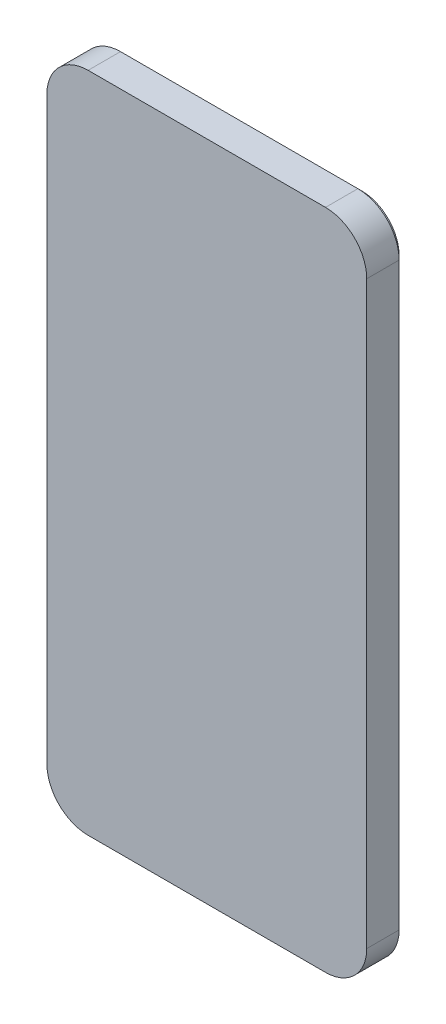
from build123d import *

# Parameters (mm, degrees)
IZIM1_W                     = 77.58
IZIM1_H                     = 160.7
Y_KSEKLIK_EKSTR_ZYON1_DEPTH = 7.85
RADYUS1_R                   = 10
Y_KSEKLIK_EKSTR_ZYON2_DEPTH = 2
Y_KSEKLIK_EKSTR_ZYON3_DEPTH = 1
RADYUS3_R                   = 0.8


with BuildPart() as part:
    # Çizim1 → Yükseklik-Ekstrüzyon1 (new body)
    with BuildSketch(Plane.XY):
        with Locations((15.94448574, -50.114448669)):
            Rectangle(IZIM1_W, IZIM1_H)
    extrude(amount=Y_KSEKLIK_EKSTR_ZYON1_DEPTH)

    # Radyus1
    radyus1_edges = [part.edges().sort_by_distance(p)[0] for p in [
        (-22.84551426, 30.235551331, 3.925),
        (54.73448574, 30.235551331, 3.925),
        (54.73448574, -130.464448669, 3.925),
        (-22.84551426, -130.464448669, 3.925),
    ]]
    fillet(radyus1_edges, radius=RADYUS1_R)

    # Çizim3 → Yükseklik-Ekstrüzyon2 (add)
    with BuildSketch(Plane(origin=(0, 0, 0), x_dir=(-1, 0, 0), z_dir=(0, 0, -1))):
        with BuildLine():
            Line((-42.73448574, 28.235551331), (-22.73448574, 28.235551331))
            ThreePointArc((-22.73448574, 28.235551331), (-15.663417928, 25.306619143), (-12.73448574, 18.235551331))
            Line((-12.73448574, 18.235551331), (-12.73448574, -1.764448669))
            ThreePointArc((-12.73448574, -1.764448669), (-15.663417928, -8.835516481), (-22.73448574, -11.764448669))
            Line((-22.73448574, -11.764448669), (-42.73448574, -11.764448669))
            ThreePointArc((-42.73448574, -11.764448669), (-49.805553552, -8.835516481), (-52.73448574, -1.764448669))
            Line((-52.73448574, -1.764448669), (-52.73448574, 18.235551331))
            ThreePointArc((-52.73448574, 18.235551331), (-49.805553552, 25.306619143), (-42.73448574, 28.235551331))
        make_face()
    extrude(amount=Y_KSEKLIK_EKSTR_ZYON2_DEPTH)

    # Çizim7 → Yükseklik-Ekstrüzyon3 (add)
    with BuildSketch(Plane(origin=(0, 0, -2), x_dir=(-1, 0, 0), z_dir=(0, 0, -1))):
        with BuildLine():
            Line((-42.73448574, 27.235551331), (-22.73448574, 27.235551331))
            ThreePointArc((-22.73448574, 27.235551331), (-16.370524709, 24.599512361), (-13.73448574, 18.235551331))
            Line((-13.73448574, 18.235551331), (-13.73448574, -1.764448669))
            ThreePointArc((-13.73448574, -1.764448669), (-16.370524709, -8.1284097), (-22.73448574, -10.764448669))
            Line((-22.73448574, -10.764448669), (-42.73448574, -10.764448669))
            ThreePointArc((-42.73448574, -10.764448669), (-49.098446771, -8.1284097), (-51.73448574, -1.764448669))
            Line((-51.73448574, -1.764448669), (-51.73448574, 18.235551331))
            ThreePointArc((-51.73448574, 18.235551331), (-49.098446771, 24.599512361), (-42.73448574, 27.235551331))
        make_face()
    extrude(amount=Y_KSEKLIK_EKSTR_ZYON3_DEPTH)

    # Radyus3
    radyus3_edges = [part.edges().sort_by_distance(p)[0] for p in [
        (49.805553552, 25.306619143, -2),
        (52.73448574, 8.235551331, -2),
        (49.805553552, -8.835516481, -2),
        (32.73448574, -11.764448669, -2),
        (15.663417928, -8.835516481, -2),
        (12.73448574, 8.235551331, -2),
        (15.663417928, 25.306619143, -2),
        (32.73448574, 28.235551331, -2),
    ]]
    fillet(radyus3_edges, radius=RADYUS3_R)


solid = part.part
